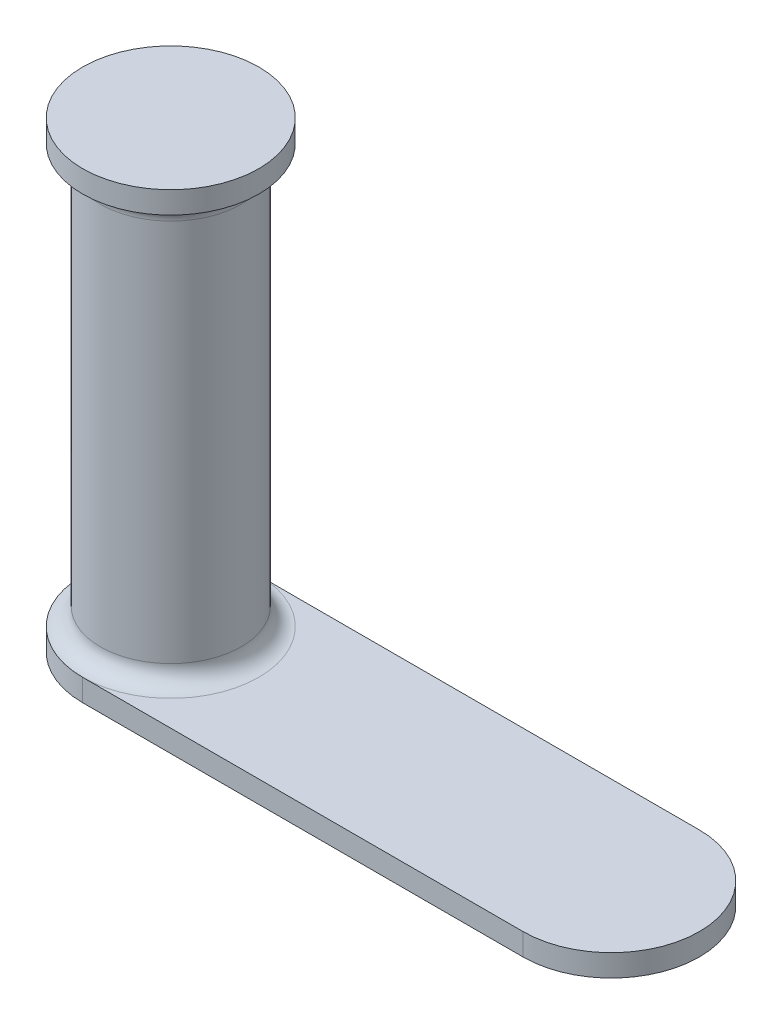
from build123d import *

# Parameters (mm, degrees)
EXTRUDE_1_DEPTH = 5


with BuildPart() as part:
    # 草图1 → 旋转1 (revolve)
    with BuildSketch(Plane.XY):
        with BuildLine():
            Line((0, 60.184685033), (0, -39.815314967))
            Line((0, -39.815314967), (20, -39.815314967))
            ThreePointArc((20, -39.815314967), (17.171572875, -38.643742092), (16, -35.815314967))
            Line((16, -35.815314967), (16, 51.184685033))
            ThreePointArc((16, 51.184685033), (17.171572875, 54.013112157), (20, 55.184685033))
            Line((20, 55.184685033), (20, 60.184685033))
            Line((20, 60.184685033), (0, 60.184685033))
        make_face()
    revolve(axis=Axis((0, 60.184685033, 0), (0, -1, 0)))

    # 草图2 → 凸台-拉伸1 (add)
    with BuildSketch(Plane.XZ.offset(39.815314967)):
        with BuildLine():
            Line((0, -20), (100, -20))
            ThreePointArc((100, -20), (120, 0), (100, 20))
            Line((100, 20), (0, 20))
            ThreePointArc((0, 20), (-20, 0), (0, -20))
        make_face()
    extrude(amount=EXTRUDE_1_DEPTH)


solid = part.part
